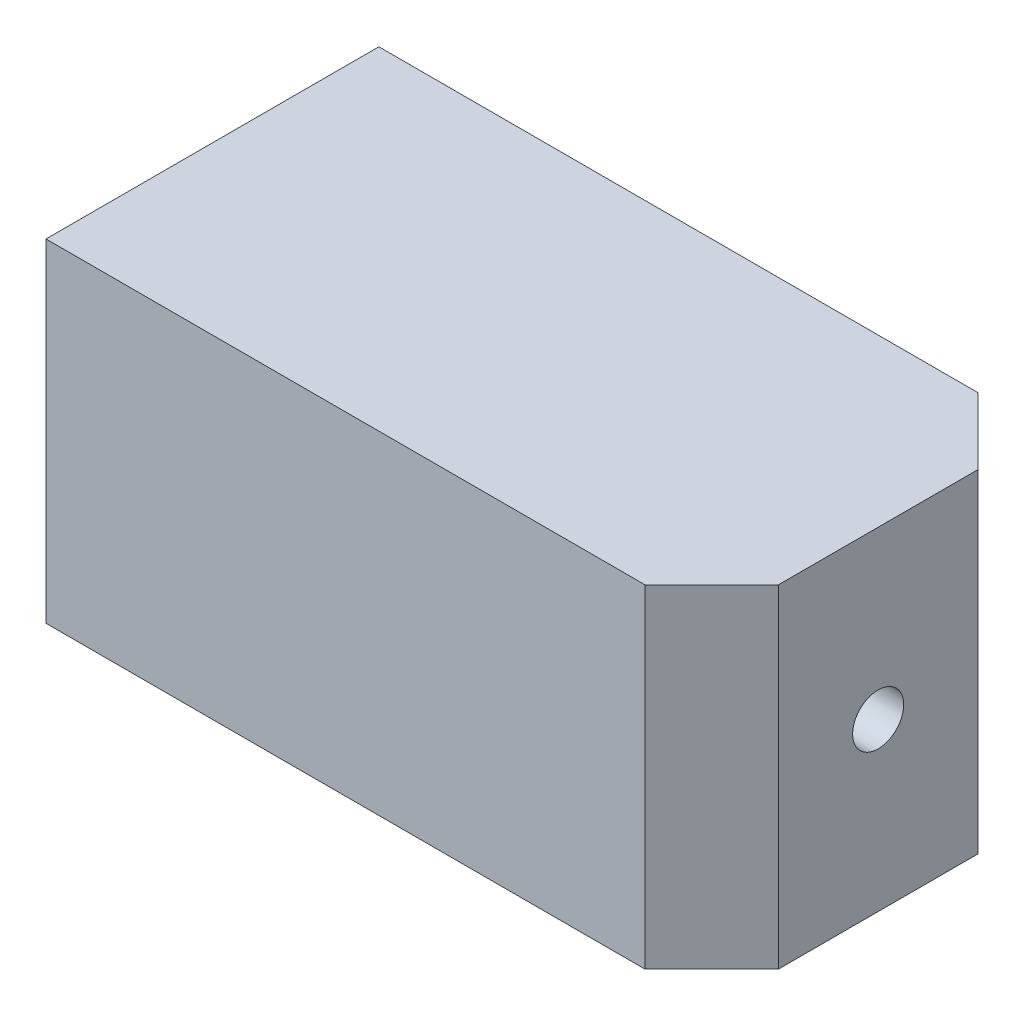
from build123d import *

# Parameters (mm, degrees)
SKETCH1_W           = 30
SKETCH1_H           = 15
BOSS_EXTRUDE1_DEPTH = 15
CHAMFER1_SIZE       = 3
SKETCH2_R           = 5
CUT_EXTRUDE1_DEPTH  = 27
SKETCH3_R           = 1.15
CUT_EXTRUDE2_DEPTH  = 7


with BuildPart() as part:
    # Sketch1 → Boss-Extrude1 (new body)
    with BuildSketch(Plane(origin=(0, 0, 0), x_dir=(1, 0, 0), z_dir=(0, 1, 0))):
        Rectangle(SKETCH1_W, SKETCH1_H)
    extrude(amount=BOSS_EXTRUDE1_DEPTH)

    # Chamfer1
    chamfer1_edges = [part.edges().sort_by_distance(p)[0] for p in [
        (15, 7.5, 7.5),
        (15, 7.5, -7.5),
    ]]
    chamfer(chamfer1_edges, length=CHAMFER1_SIZE)

    # Sketch2 → Cut-Extrude1 (cut)
    with BuildSketch(Plane.ZY.offset(15)):
        with Locations((0, 7.5)):
            Circle(SKETCH2_R)
    extrude(amount=-CUT_EXTRUDE1_DEPTH, mode=Mode.SUBTRACT)

    # Sketch3 → Cut-Extrude2 (cut)
    with BuildSketch(Plane.ZY.offset(-12)):
        with Locations((0, 7.5)):
            Circle(SKETCH3_R)
    extrude(amount=-CUT_EXTRUDE2_DEPTH, mode=Mode.SUBTRACT)


solid = part.part
